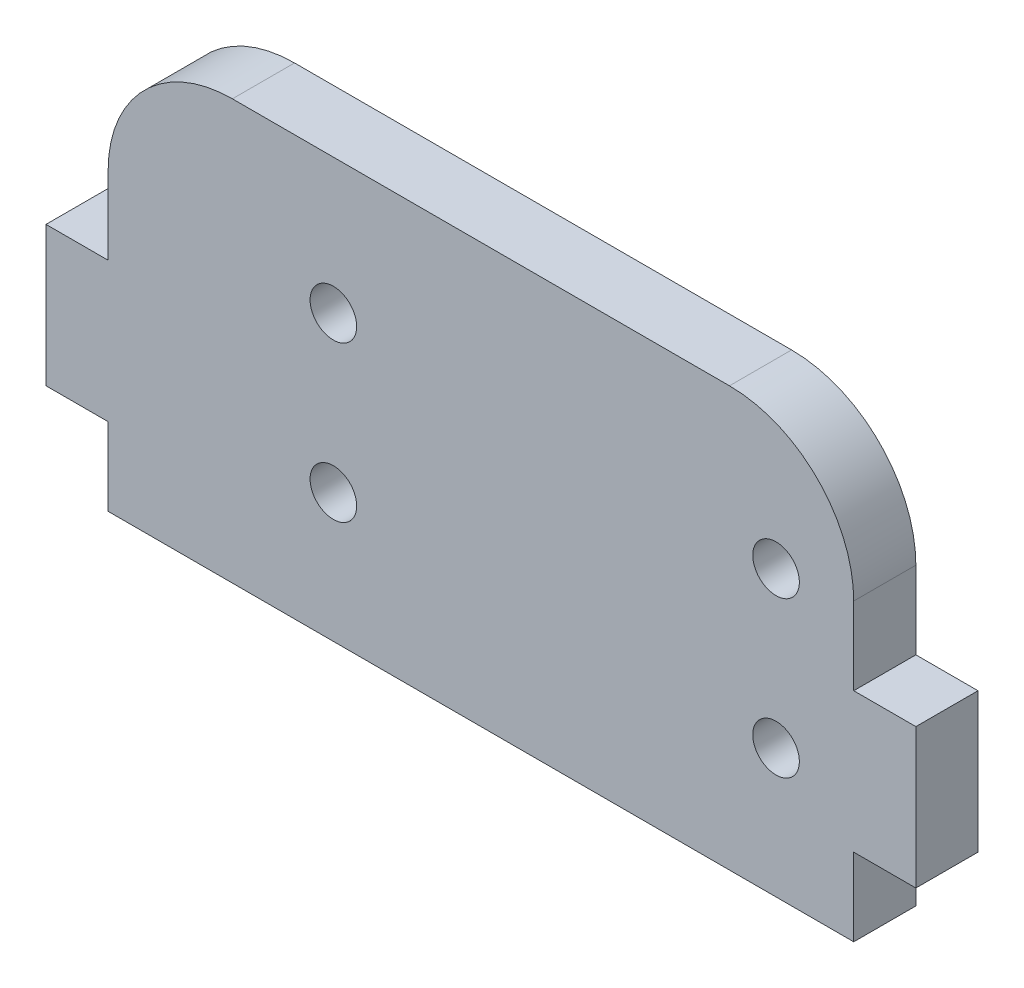
from build123d import *

# Parameters (mm, degrees)
SKETCH1_R           = 1.5
BOSS_EXTRUDE1_DEPTH = 4


with BuildPart() as part:
    # Sketch1 → Boss-Extrude1 (new body)
    with BuildSketch(Plane.XY):
        with BuildLine():
            Line((3.999999567, 13.999999851), (-4.33e-07, 13.999999851))
            Line((-4.33e-07, 13.999999851), (-4.33e-07, 4.999999851))
            Line((-4.33e-07, 4.999999851), (3.999999567, 4.999999851))
            Line((3.999999567, 4.999999851), (3.999999567, -1.49e-07))
            Line((3.999999567, -1.49e-07), (51.999999567, -1.49e-07))
            Line((51.999999567, -1.49e-07), (51.999999567, 4.999999851))
            Line((51.999999567, 4.999999851), (55.999999567, 4.999999851))
            Line((55.999999567, 4.999999851), (55.999999567, 13.999999851))
            Line((55.999999567, 13.999999851), (51.999999567, 13.999999851))
            Line((51.999999567, 13.999999851), (51.999999567, 18.999999851))
            ThreePointArc((51.999999567, 18.999999851), (49.656853817, 24.6568541), (43.999999567, 26.999999851))
            Line((43.999999567, 26.999999851), (11.999999567, 26.999999851))
            ThreePointArc((11.999999567, 26.999999851), (6.343145318, 24.6568541), (3.999999567, 18.999999851))
            Line((3.999999567, 18.999999851), (3.999999567, 13.999999851))
        make_face()
        with Locations((46.999999567, 18.299999851)):
            Circle(SKETCH1_R, mode=Mode.SUBTRACT)
        with Locations((46.999999567, 8.299999851)):
            Circle(SKETCH1_R, mode=Mode.SUBTRACT)
        with Locations((18.499999567, 18.299999851)):
            Circle(SKETCH1_R, mode=Mode.SUBTRACT)
        with Locations((18.499999567, 8.299999851)):
            Circle(SKETCH1_R, mode=Mode.SUBTRACT)
    extrude(amount=BOSS_EXTRUDE1_DEPTH)


solid = part.part
